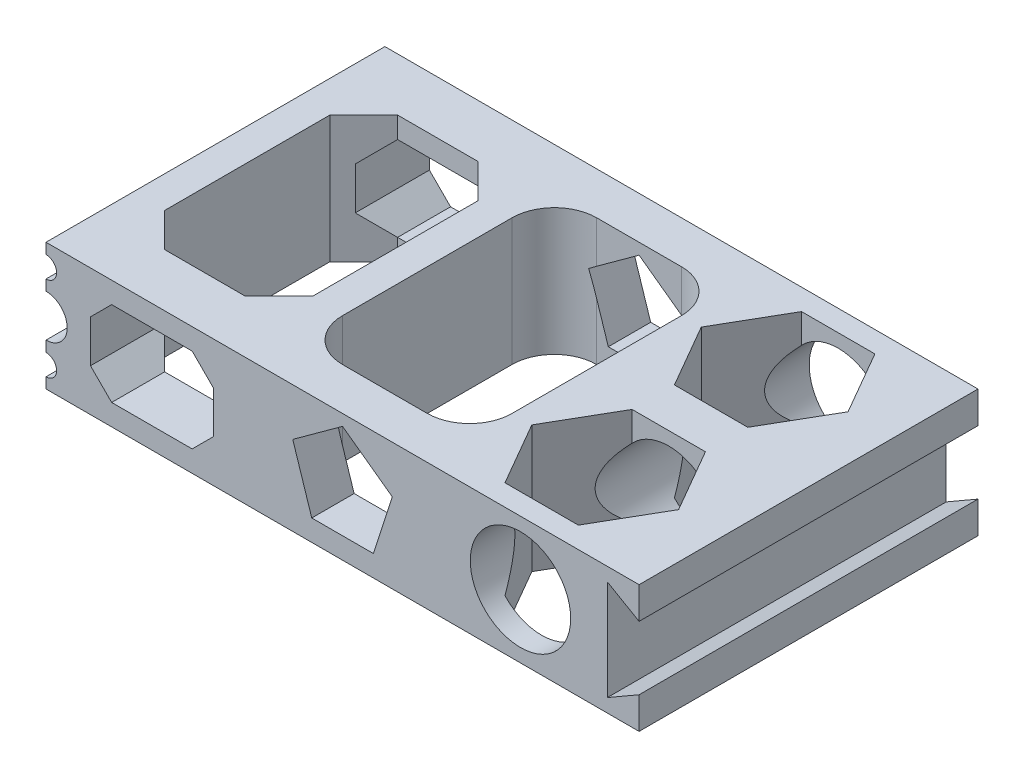
from build123d import *

# Parameters (mm, degrees)
SKETCH1_W           = 177.8
SKETCH1_H           = 101.6
BOSS_EXTRUDE1_DEPTH = 19.05
CUT_EXTRUDE1_DEPTH  = 39.1
SKETCH3_R           = 3.175
SKETCH3_R_2         = 6.35
SKETCH3_R_3         = 15.0495
CUT_EXTRUDE2_DEPTH  = 102.6


with BuildPart() as part:
    # Sketch1 → Boss-Extrude1 (new body, symmetric)
    with BuildSketch(Plane(origin=(0, 0, 0), x_dir=(1, 0, 0), z_dir=(0, 1, 0))):
        Rectangle(SKETCH1_W, SKETCH1_H)
    extrude(amount=BOSS_EXTRUDE1_DEPTH, both=True)

    # Sketch2 → Cut-Extrude1 (cut, through all)
    with BuildSketch(Plane(origin=(0, 19.05, 0), x_dir=(1, 0, 0), z_dir=(0, 1, 0))):
        Polygon((-79.375, 24.765), (-69.215, 34.925), (-45.085, 34.925), (-34.925, 24.765), (-34.925, -24.765), (-45.085, -34.925), (-69.215, -34.925), (-79.375, -24.765), align=None)
        with BuildLine():
            Line((-12.7, 38.1), (12.7, 38.1))
            ThreePointArc((12.7, 38.1), (21.680256121, 34.380256121), (25.4, 25.4))
            Line((25.4, 25.4), (25.4, -25.4))
            ThreePointArc((25.4, -25.4), (21.680256121, -34.380256121), (12.7, -38.1))
            Line((12.7, -38.1), (-12.7, -38.1))
            ThreePointArc((-12.7, -38.1), (-21.680256121, -34.380256121), (-25.4, -25.4))
            Line((-25.4, -25.4), (-25.4, 25.4))
            ThreePointArc((-25.4, 25.4), (-21.680256121, 34.380256121), (-12.7, 38.1))
        make_face()
        Polygon((64.338522628, 6.35), (75.337045256, 25.4), (64.338522628, 44.45), (42.341477372, 44.45), (31.342954744, 25.4), (42.341477372, 6.35), align=None)
        Polygon((42.341477372, -6.35), (64.338522628, -6.35), (75.337045256, -25.4), (64.338522628, -44.45), (42.341477372, -44.45), (31.342954744, -25.4), align=None)
    extrude(amount=-CUT_EXTRUDE1_DEPTH, mode=Mode.SUBTRACT)

    # Sketch3 → Cut-Extrude2 (cut, through all)
    with BuildSketch(Plane.XY.offset(50.8)):
        with Locations((-88.9, 12.7)):
            Circle(SKETCH3_R)
        with Locations((-88.9, 0)):
            Circle(SKETCH3_R_2)
        with Locations((-88.9, -12.7)):
            Circle(SKETCH3_R)
        with Locations((53.34, 0)):
            Circle(SKETCH3_R_3)
        Polygon((-75.565, 6.35), (-69.215, 12.7), (-45.085, 12.7), (-38.735, 6.35), (-38.735, -6.35), (-45.085, -12.7), (-69.215, -12.7), (-75.565, -6.35), align=None)
        Polygon((9.227090106, -12.7), (14.929745408, 4.850968343), (0, 15.698063314), (-14.929745408, 4.850968343), (-9.227090106, -12.7), align=None)
        Polygon((88.9, 9.525), (79.375, 15.024261314), (79.375, -15.024261314), (88.9, -9.525), align=None)
    extrude(amount=-CUT_EXTRUDE2_DEPTH, mode=Mode.SUBTRACT)


solid = part.part
